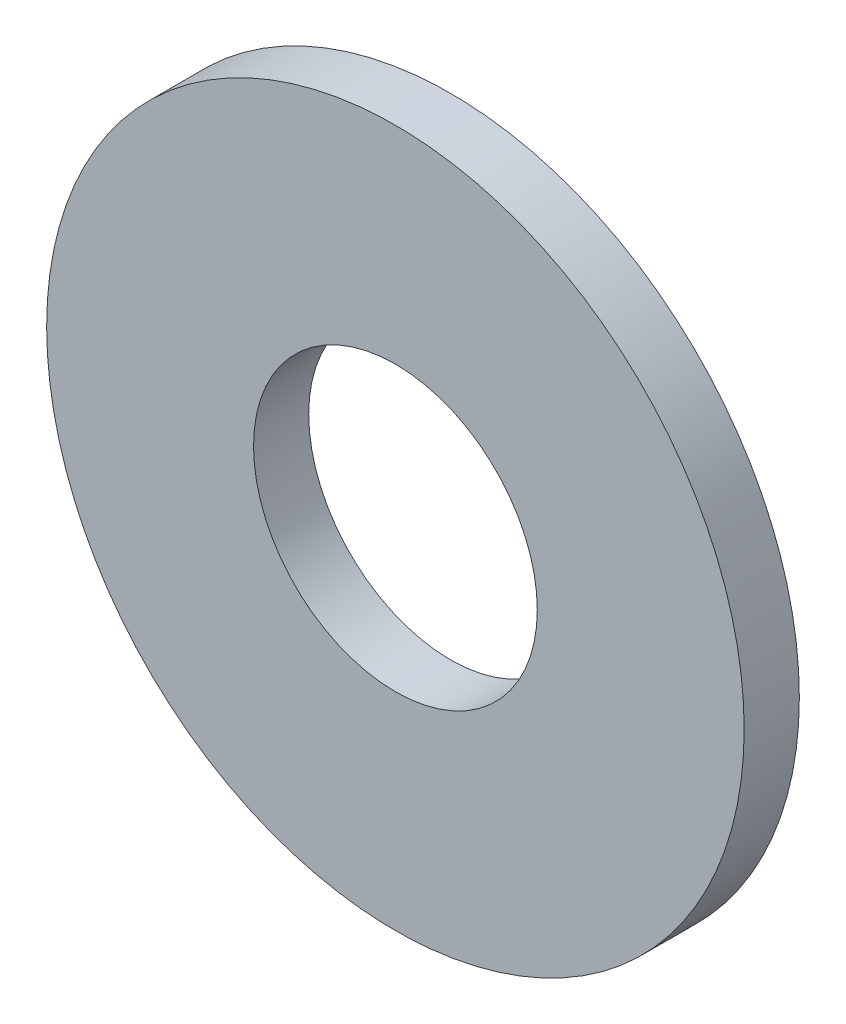
from build123d import *

# Parameters (mm, degrees)
SKETCH1_R           = 8.85
SKETCH1_R_2         = 3.6
BOSS_EXTRUDE1_DEPTH = 1.4


with BuildPart() as part:
    # Sketch1 → Boss-Extrude1 (new body)
    with BuildSketch(Plane.XY):
        Circle(SKETCH1_R)
        Circle(SKETCH1_R_2, mode=Mode.SUBTRACT)
    extrude(amount=BOSS_EXTRUDE1_DEPTH)


solid = part.part
